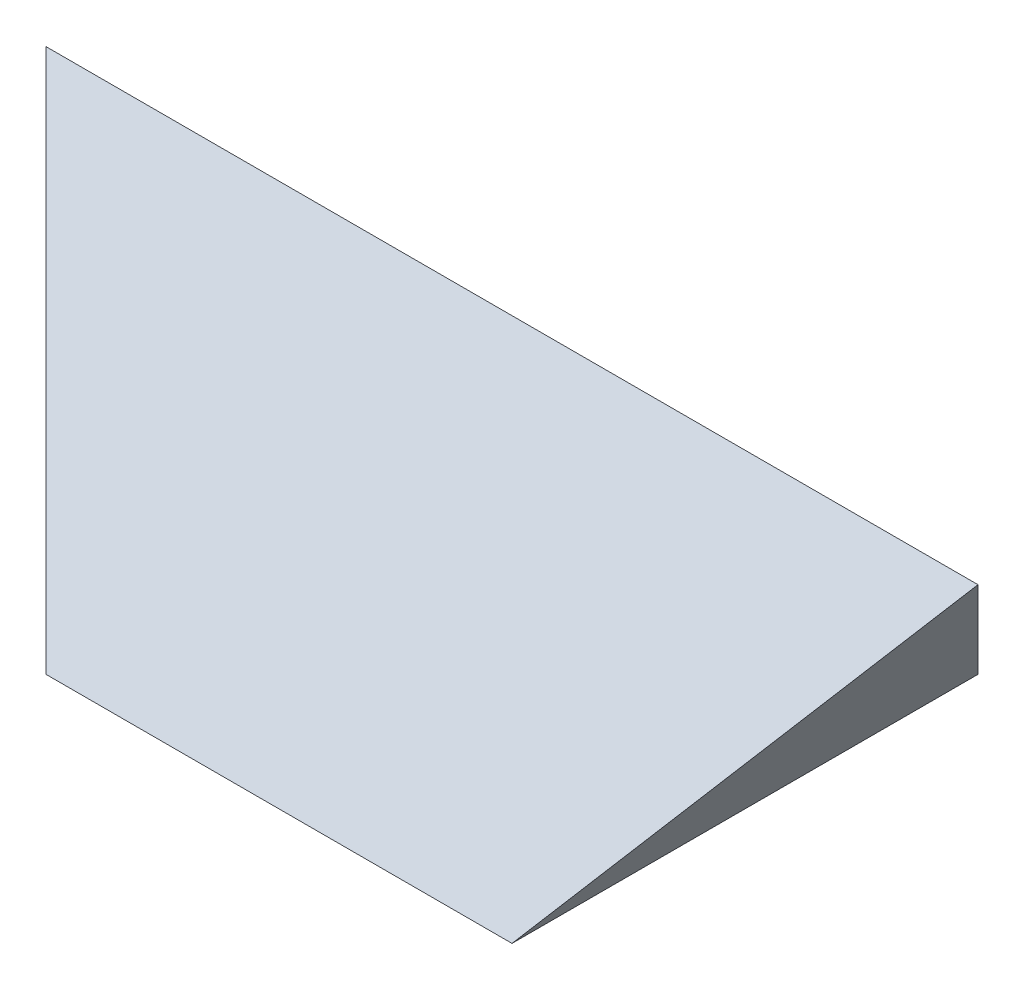
from build123d import *

# Parameters (mm, degrees)
SKETCH1_W           = 60
SKETCH1_H           = 20
BOSS_EXTRUDE1_DEPTH = 15
CUT_EXTRUDE1_DEPTH  = 22
CUT_EXTRUDE2_DEPTH  = 34


with BuildPart() as part:
    # Sketch1 → Boss-Extrude1 (new body, symmetric)
    with BuildSketch(Plane.XY):
        Rectangle(SKETCH1_W, SKETCH1_H)
    extrude(amount=BOSS_EXTRUDE1_DEPTH, both=True)

    # Sketch2 → Cut-Extrude1 (cut, symmetric)
    with BuildSketch(Plane.XY):
        Polygon((-15, -10), (-30, 10), (-30, -10), align=None)
        Polygon((15, -10), (30, 10), (30, -10), align=None)
    extrude(amount=CUT_EXTRUDE1_DEPTH, both=True, mode=Mode.SUBTRACT)

    # Sketch3 → Cut-Extrude2 (cut, symmetric)
    with BuildSketch(Plane(origin=(0, 0, 0), x_dir=(0, 0, -1), z_dir=(1, 0, 0))):
        Polygon((-15, 10), (-15, -10), (0, 10), align=None)
        Polygon((15, 10), (0, 10), (15, -10), align=None)
    extrude(amount=CUT_EXTRUDE2_DEPTH, both=True, mode=Mode.SUBTRACT)


solid = part.part
